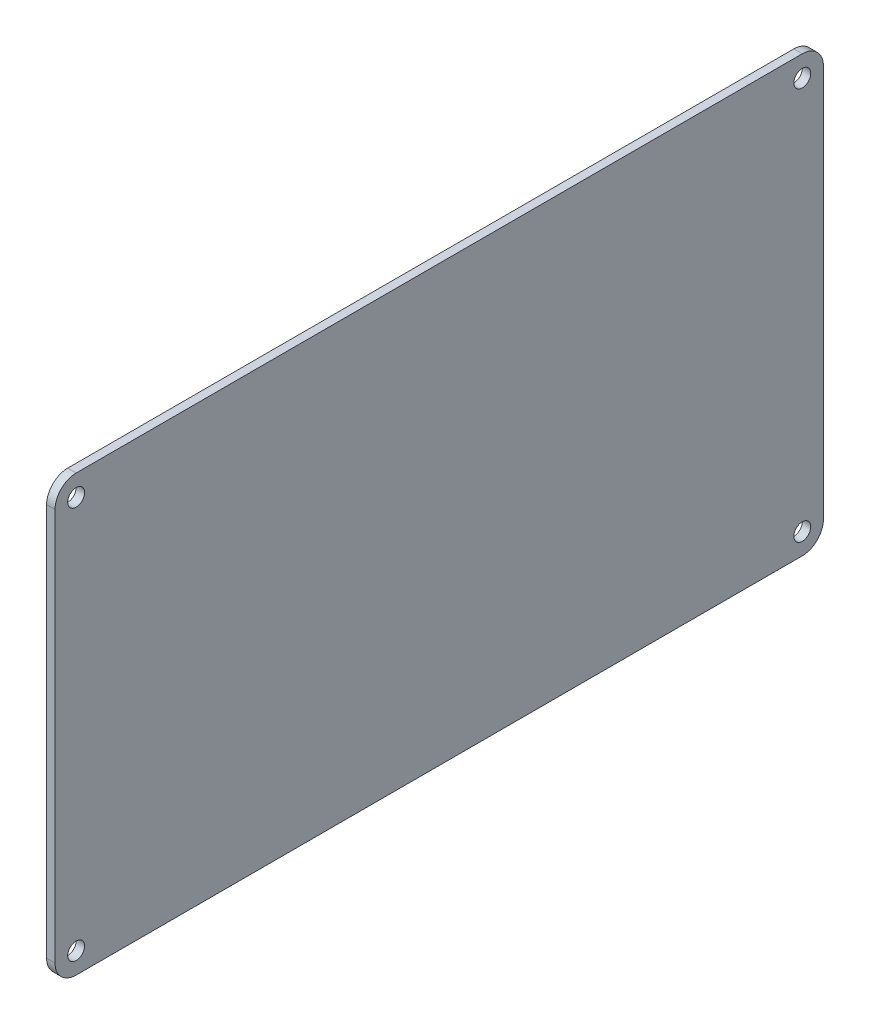
from build123d import *

# Parameters (mm, degrees)
SKETCH1_W           = 103
SKETCH1_H           = 2
BOSS_EXTRUDE1_DEPTH = 182
SKETCH2_R           = 2
CUT_EXTRUDE1_DEPTH  = 168
FILLET1_R           = 5
FILLET2_R           = 5
FILLET3_R           = 5
FILLET4_R           = 5


with BuildPart() as part:
    # Sketch1 → Boss-Extrude1 (new body)
    with BuildSketch(Plane(origin=(0, 0, 0), x_dir=(0, 1, 0), z_dir=(0, 0, 1))):
        with Locations((42.672413793, 1)):
            Rectangle(SKETCH1_W, SKETCH1_H)
    extrude(amount=BOSS_EXTRUDE1_DEPTH)

    # Sketch2 → Cut-Extrude1 (cut)
    with BuildSketch(Plane.YZ):
        with Locations((-3.827586207, 177)):
            Circle(SKETCH2_R)
        with Locations((89.172413793, 177)):
            Circle(SKETCH2_R)
        with Locations((89.172413793, 5)):
            Circle(SKETCH2_R)
        with Locations((-3.827586207, 5)):
            Circle(SKETCH2_R)
    extrude(amount=-CUT_EXTRUDE1_DEPTH, mode=Mode.SUBTRACT)

    # Fillet1
    fillet1_edges = [part.edges().sort_by_distance(p)[0] for p in [
        (-1, -8.827586207, 182),
    ]]
    fillet(fillet1_edges, radius=FILLET1_R)

    # Fillet2
    fillet2_edges = [part.edges().sort_by_distance(p)[0] for p in [
        (-1, 94.172413793, 182),
    ]]
    fillet(fillet2_edges, radius=FILLET2_R)

    # Fillet3
    fillet3_edges = [part.edges().sort_by_distance(p)[0] for p in [
        (-1, 94.172413793, 0),
    ]]
    fillet(fillet3_edges, radius=FILLET3_R)

    # Fillet4
    fillet4_edges = [part.edges().sort_by_distance(p)[0] for p in [
        (-1, -8.827586207, 0),
    ]]
    fillet(fillet4_edges, radius=FILLET4_R)


solid = part.part
